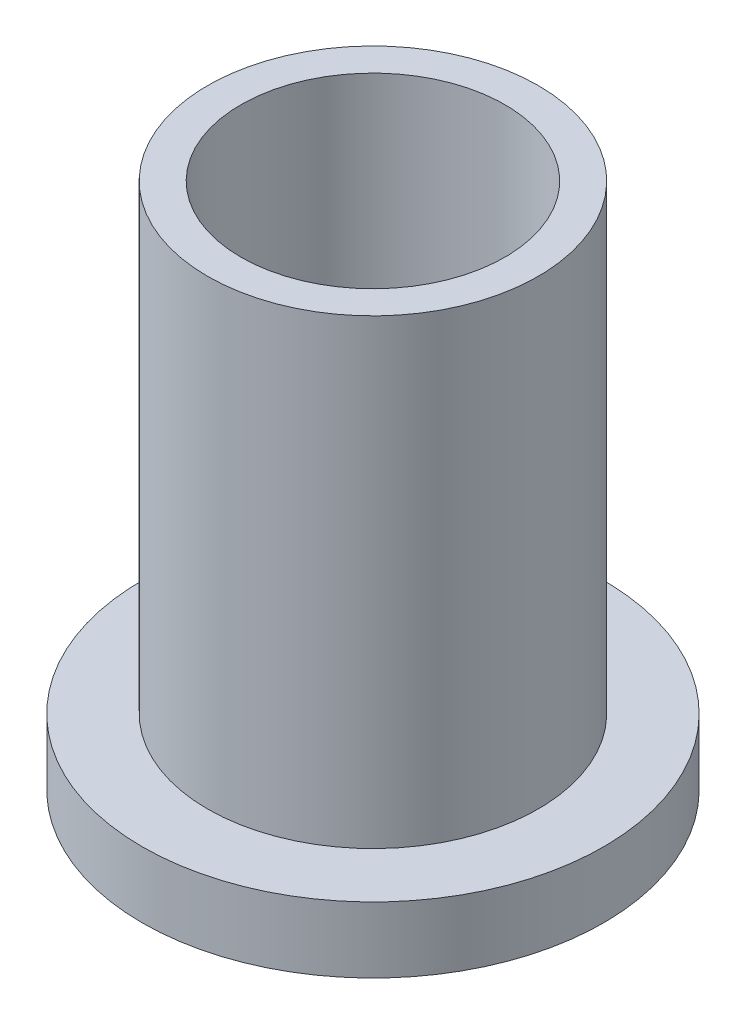
from build123d import *

# Parameters (mm, degrees)
SKETCH2_R           = 7.9629
SKETCH2_R_2         = 6.3627
BOSS_EXTRUDE1_DEPTH = 25.4
SKETCH3_R           = 11.1125
SKETCH3_R_2         = 7.9629
BOSS_EXTRUDE2_DEPTH = 3.175


with BuildPart() as part:
    # Sketch2 → Boss-Extrude1 (new body)
    with BuildSketch(Plane(origin=(0, 0, 0), x_dir=(1, 0, 0), z_dir=(0, 1, 0))):
        Circle(SKETCH2_R)
        Circle(SKETCH2_R_2, mode=Mode.SUBTRACT)
    extrude(amount=BOSS_EXTRUDE1_DEPTH)

    # Sketch3 → Boss-Extrude2 (add)
    with BuildSketch(Plane(origin=(0, 0, 0), x_dir=(1, 0, 0), z_dir=(0, 1, 0))):
        Circle(SKETCH3_R)
        Circle(SKETCH3_R_2, mode=Mode.SUBTRACT)
    extrude(amount=BOSS_EXTRUDE2_DEPTH)


solid = part.part
